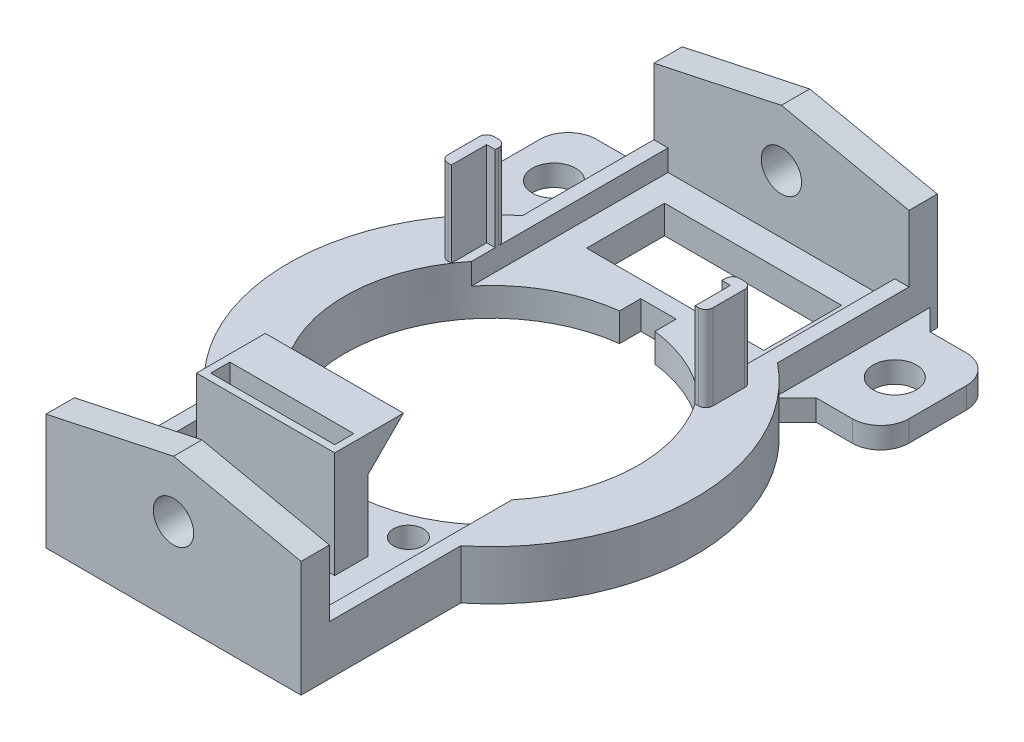
from build123d import *

# Parameters (mm, degrees)
BOSS_EXTRUDE1_DEPTH  = 89.8
SKETCH5_R            = 2.85
BOSS_EXTRUDE2_DEPTH  = 4
SKETCH6_W            = 25
SKETCH6_H            = 11
CUT_EXTRUDE4_DEPTH   = 5
SKETCH8_W            = 19.5
SKETCH8_H            = 4.7
SKETCH8_W_2          = 17.5
SKETCH8_H_2          = 2.7
BOSS_EXTRUDE3_DEPTH  = 15
BOSS_EXTRUDE4_DEPTH  = 19.5
SKETCH13_W           = 17.5
SKETCH13_H           = 2.7
CUT_EXTRUDE5_DEPTH   = 5
SKETCH14_W           = 12.1
SKETCH14_H           = 16.1
SKETCH14_R           = 3.05
BOSS_EXTRUDE7_DEPTH  = 3
CHAMFER1_SIZE        = 3
SKETCH17_R           = 2.1
CUT_EXTRUDE6_DEPTH   = 5
BOSS_EXTRUDE8_DEPTH  = 7
CUT_EXTRUDE7_REACH   = 22.21
SKETCH20_R           = 20.7
FILLET1_R            = 4
SKETCH21_R           = 2.1
CUT_EXTRUDE8_DEPTH   = 5
SKETCH22_W           = 5
SKETCH22_H           = 3
CUT_EXTRUDE9_DEPTH   = 5
BOSS_EXTRUDE9_DEPTH  = 12
FILLET2_R            = 1
FILLET2_OF_MIRROR3_R = 1


with BuildPart() as part:
    # Sketch1 → Boss-Extrude1 (new body)
    with BuildSketch(Plane.XY):
        Polygon((-18, 114.78957189), (0, 114.78957189), (18, 114.78957189), (18, 121.78957189), (16, 121.78957189), (16, 118.78957189), (-16, 118.78957189), (-16, 121.78957189), (-18, 121.78957189), align=None)
    extrude(amount=BOSS_EXTRUDE1_DEPTH)

    # Sketch5 → Boss-Extrude2 (add)
    with BuildSketch(Plane.XY):
        Polygon((-18, 114.78957189), (-18, 131.151236874), (0, 135), (18, 131.151236874), (18, 114.78957189), align=None)
        with Locations((0, 127)):
            Circle(SKETCH5_R, mode=Mode.SUBTRACT)
    boss_extrude2 = extrude(amount=BOSS_EXTRUDE2_DEPTH)

    # Mirror1: Boss-Extrude2 across plane
    add(boss_extrude2.mirror(Plane(origin=(0, 0, 44.9), x_dir=(1, 0, 0), z_dir=(0, 0, -1))))

    # Sketch6 → Cut-Extrude4 (cut, through all)
    with BuildSketch(Plane(origin=(0, 118.78957189, 0), x_dir=(1, 0, 0), z_dir=(0, 1, 0))):
        with Locations((0, -13.5)):
            Rectangle(SKETCH6_W, SKETCH6_H)
    extrude(amount=-CUT_EXTRUDE4_DEPTH, mode=Mode.SUBTRACT)

    # Sketch8 → Boss-Extrude3 (add)
    with BuildSketch(Plane(origin=(0, 118.78957189, 0), x_dir=(1, 0, 0), z_dir=(0, 1, 0))):
        with Locations((0, -74.45)):
            Rectangle(SKETCH8_W, SKETCH8_H)
        with Locations((0, -74.45)):
            Rectangle(SKETCH8_W_2, SKETCH8_H_2, mode=Mode.SUBTRACT)
    extrude(amount=BOSS_EXTRUDE3_DEPTH)

    # Sketch9 → Boss-Extrude4 (add)
    with BuildSketch(Plane.ZY.offset(9.75)):
        Polygon((72.1, 128.78957189), (67.1, 133.78957189), (72.1, 133.78957189), align=None)
    extrude(amount=-BOSS_EXTRUDE4_DEPTH)

    # Sketch13 → Cut-Extrude5 (cut, through all)
    with BuildSketch(Plane(origin=(0, 118.78957189, 0), x_dir=(1, 0, 0), z_dir=(0, 1, 0))):
        with Locations((0, -74.45)):
            Rectangle(SKETCH13_W, SKETCH13_H)
    extrude(amount=-CUT_EXTRUDE5_DEPTH, mode=Mode.SUBTRACT)

    # Sketch14 → Boss-Extrude7 (add)
    with BuildSketch(Plane(origin=(0, 114.78957189, 0), x_dir=(1, 0, 0), z_dir=(0, 1, 0))):
        with Locations((-24.05, -12.05)):
            Rectangle(SKETCH14_W, SKETCH14_H)
        with Locations((-24.05, -12.05)):
            Circle(SKETCH14_R, mode=Mode.SUBTRACT)
    boss_extrude7 = extrude(amount=BOSS_EXTRUDE7_DEPTH)

    # Mirror2: Boss-Extrude7 across plane
    add(boss_extrude7.mirror(Plane(origin=(0, 0, 0), x_dir=(0, 0, 1), z_dir=(1, 0, 0))))

    # Chamfer1
    chamfer1_edges = [part.edges().sort_by_distance(p)[0] for p in [
        (-18, 116.28957189, 20.1),
        (-18, 116.28957189, 4),
        (18, 116.28957189, 4),
        (18, 116.28957189, 20.1),
    ]]
    chamfer(chamfer1_edges, length=CHAMFER1_SIZE)

    # Sketch17 → Cut-Extrude6 (cut, through all)
    with BuildSketch(Plane(origin=(0, 118.78957189, 0), x_dir=(1, 0, 0), z_dir=(0, 1, 0))):
        with Locations((0, -81.15)):
            Circle(SKETCH17_R)
    extrude(amount=-CUT_EXTRUDE6_DEPTH, mode=Mode.SUBTRACT)

    # Sketch19 → Boss-Extrude8 (add)
    with BuildSketch(Plane.XZ.offset(-114.78957189)):
        with BuildLine():
            Line((18, 67.25374689), (18, 55.122035022))
            ThreePointArc((18, 55.122035022), (20.7, 44.9), (18, 34.677964978))
            Line((18, 34.677964978), (18, 22.54625311))
            ThreePointArc((18, 22.54625311), (28.7, 44.9), (18, 67.25374689))
        make_face()
        with BuildLine():
            Line((-16, 68.726246032), (-16, 58.033544838))
            ThreePointArc((-16, 58.033544838), (-20.624518846, 46.666132031), (-18, 34.677964978))
            Line((-18, 34.677964978), (-18, 22.54625311))
            ThreePointArc((-18, 22.54625311), (-28.673122198, 46.141798467), (-16, 68.726246032))
        make_face()
    extrude(amount=-BOSS_EXTRUDE8_DEPTH)

    # Sketch20 → Cut-Extrude7 (cut, up to next)
    with BuildSketch(Plane.XZ.offset(-114.78957189), mode=Mode.PRIVATE) as cut_extrude7_sk1:
        with Locations((0, 44.9)):
            Circle(SKETCH20_R)
    cut_extrude7_tool1 = extrude(cut_extrude7_sk1.sketch, amount=-CUT_EXTRUDE7_REACH, mode=Mode.PRIVATE) & part.part
    add(cut_extrude7_tool1.solids().sort_by_distance((0, 114.789572, 44.9))[0], mode=Mode.SUBTRACT)

    # Fillet1
    fillet1_edges = [part.edges().sort_by_distance(p)[0] for p in [
        (-30.1, 116.28957189, 4),
        (-30.1, 116.28957189, 20.1),
        (30.1, 116.28957189, 20.1),
        (30.1, 116.28957189, 4),
    ]]
    fillet(fillet1_edges, radius=FILLET1_R)

    # Sketch21 → Cut-Extrude8 (cut, through all)
    with BuildSketch(Plane(origin=(0, 118.78957189, 0), x_dir=(1, 0, 0), z_dir=(0, 1, 0))):
        with Locations((-10.26962376, -66.923279225)):
            Circle(SKETCH21_R)
        with Locations((10.26962376, -66.923279225)):
            Circle(SKETCH21_R)
    extrude(amount=-CUT_EXTRUDE8_DEPTH, mode=Mode.SUBTRACT)

    # Sketch22 → Cut-Extrude9 (cut, through all)
    with BuildSketch(Plane(origin=(0, 118.78957189, 0), x_dir=(1, 0, 0), z_dir=(0, 1, 0))):
        with Locations((0, -66.948479262)):
            Rectangle(SKETCH22_W, SKETCH22_H)
        with Locations((0, -22.851520738)):
            Rectangle(SKETCH22_W, SKETCH22_H)
    extrude(amount=-CUT_EXTRUDE9_DEPTH, mode=Mode.SUBTRACT)

    # Sketch23 → Boss-Extrude9 (add)
    with BuildSketch(Plane(origin=(0, 121.78957189, 0), x_dir=(1, 0, 0), z_dir=(0, 1, 0))):
        Polygon((-18.7, -26.9), (-16, -26.9), (-16, -28.4), (-17.2, -28.4), (-17.2, -33.382621826), (-18.7, -33.382621826), align=None)
    boss_extrude9 = extrude(amount=BOSS_EXTRUDE9_DEPTH)

    # Fillet2
    fillet2_edges = [part.edges().sort_by_distance(p)[0] for p in [
        (-16, 127.78957189, 26.9),
        (-18.7, 127.78957189, 33.382621826),
        (-18.7, 127.78957189, 26.9),
    ]]
    fillet(fillet2_edges, radius=FILLET2_R)

    # Mirror3: Boss-Extrude9 across plane
    add(boss_extrude9.mirror(Plane(origin=(0, 0, 0), x_dir=(0, 0, 1), z_dir=(1, 0, 0))))

    # Fillet2 of Mirror3
    fillet2_of_mirror3_edges = [part.edges().sort_by_distance(p)[0] for p in [
        (16, 127.78957189, 26.9),
        (18.7, 127.78957189, 33.382621826),
        (18.7, 127.78957189, 26.9),
    ]]
    fillet(fillet2_of_mirror3_edges, radius=FILLET2_OF_MIRROR3_R)


solid = part.part
